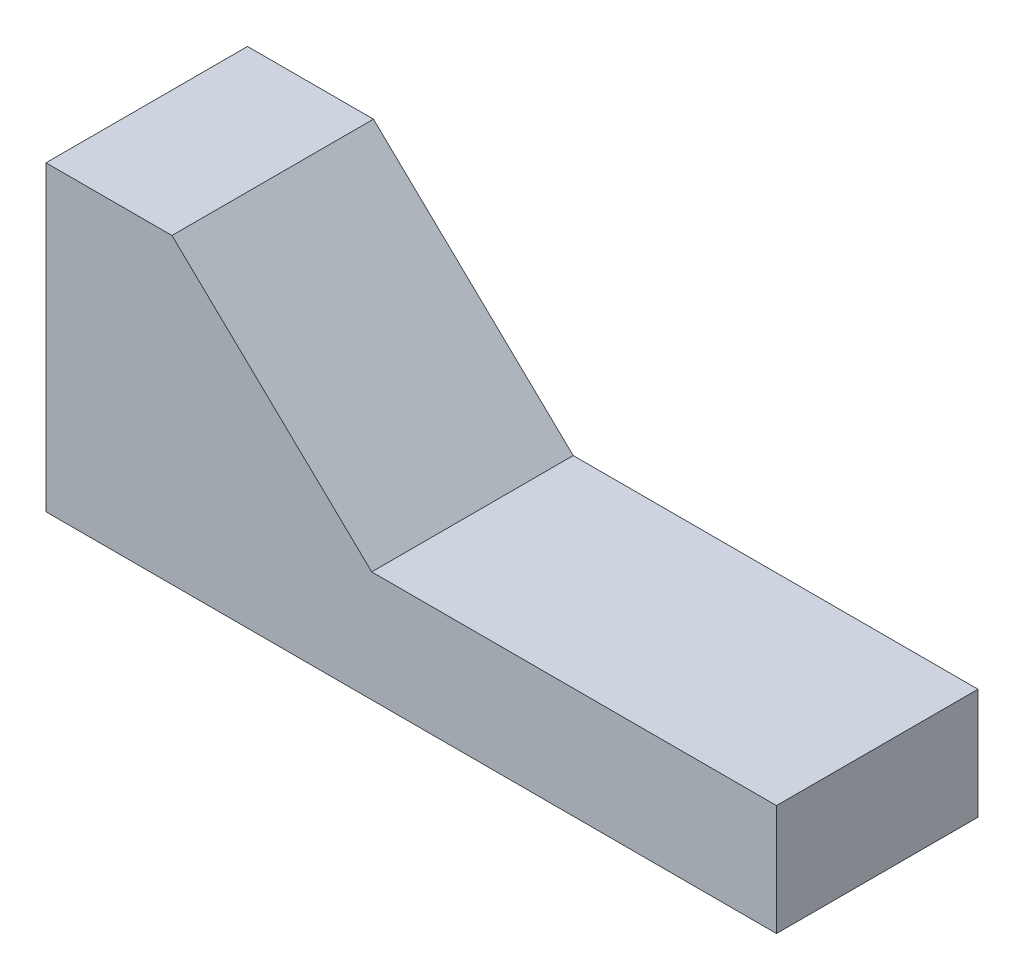
from build123d import *

# Parameters (mm, degrees)
BOSS_EXTRUDE1_DEPTH      = 20
BOSS_EXTRUDE1_DEPTH_BACK = 20


with BuildPart() as part:
    # Sketch1 → Boss-Extrude1 (new, two sides: drawn at the far end of the back side and taken through both)
    with BuildSketch(Plane.XY.offset(-BOSS_EXTRUDE1_DEPTH_BACK)):
        Polygon((-72.5, 30), (-47.5, 30), (-7.844469981, -8), (72.5, -8), (72.5, -30), (-72.5, -30), align=None)
    extrude(amount=BOSS_EXTRUDE1_DEPTH + BOSS_EXTRUDE1_DEPTH_BACK)


solid = part.part
